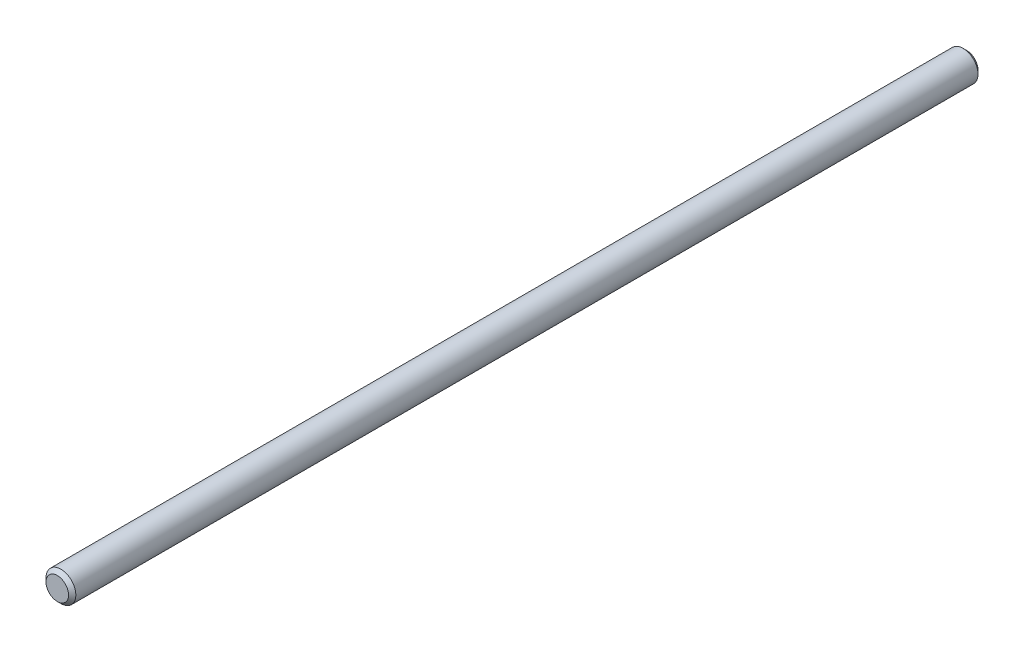
from build123d import *

# Parameters (mm, degrees)
SKETCH1_R           = 4.1
BOSS_EXTRUDE1_DEPTH = 250
CHAMFER1_SIZE       = 1


with BuildPart() as part:
    # Sketch1 → Boss-Extrude1 (new body)
    with BuildSketch(Plane.XY):
        Circle(SKETCH1_R)
    extrude(amount=BOSS_EXTRUDE1_DEPTH)

    # Chamfer1
    chamfer1_edges = [part.edges().sort_by_distance(p)[0] for p in [
        (-4.1, 0, 0),
        (-4.1, 0, 250),
    ]]
    chamfer(chamfer1_edges, length=CHAMFER1_SIZE)


solid = part.part
